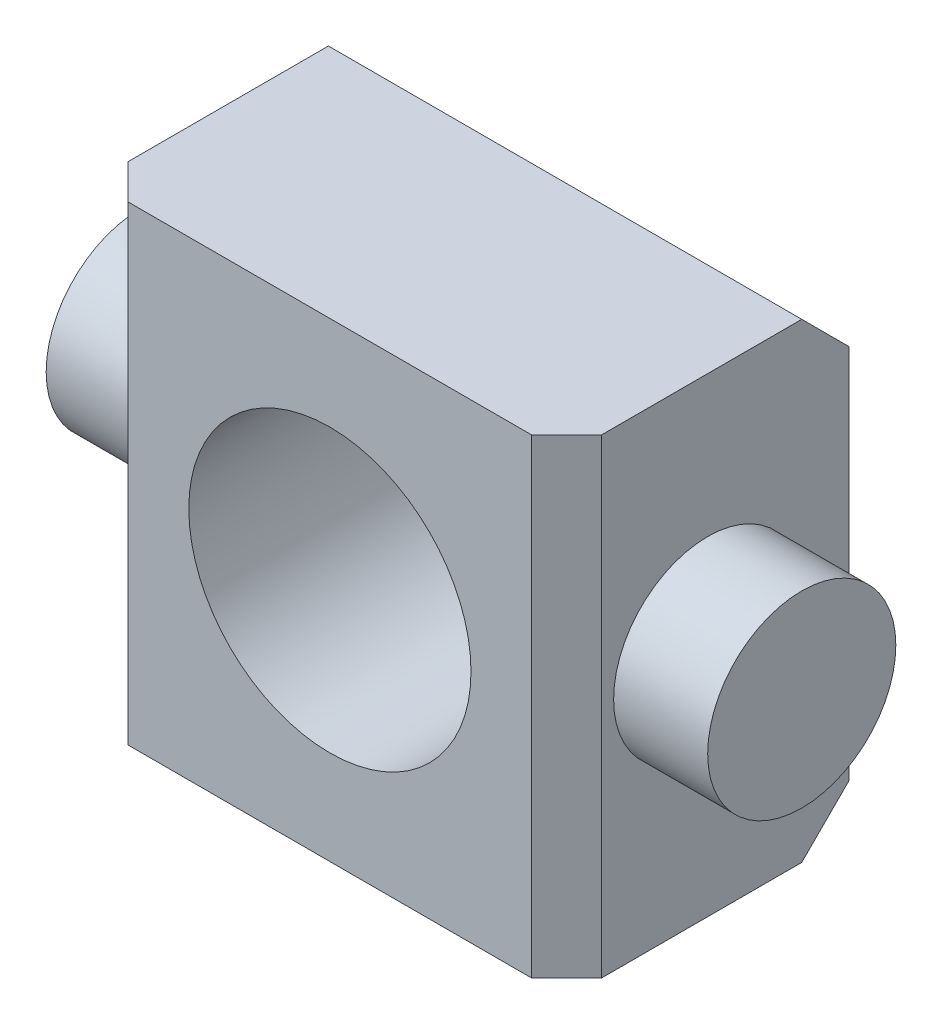
from build123d import *

# Parameters (mm, degrees)
SKETCH1_W                          = 31.9532
SKETCH1_H                          = 31.75
EXTRUDE1_DEPTH                     = 9.525
SKETCH2_R                          = 6.35
EXTRUDE2_DEPTH                     = 6.35
CHAMFER1_SIZE                      = 3.175
F_3_4_10_ACME_2C_RH_TAPPED_HOLE1_D = 19.05
CHAMFER2_SIZE                      = 2.3622


with BuildPart() as part:
    # Sketch1 → Extrude1 (new body, symmetric)
    with BuildSketch(Plane.XY):
        Rectangle(SKETCH1_W, SKETCH1_H)
    extrude(amount=EXTRUDE1_DEPTH, both=True)

    # Sketch2 → Extrude2 (add)
    with BuildSketch(Plane.ZY.offset(15.9766)):
        with Locations(Location((0, 0, 0), (0, 0, 90))):  # turned: the seam where the file's is
            Circle(SKETCH2_R)
    extrude2 = extrude(amount=EXTRUDE2_DEPTH)

    # Mirror1: Extrude2 across plane
    add(extrude2.mirror(Plane(origin=(0, 0, 0), x_dir=(0, 0, 1), z_dir=(1, 0, 0))))

    # Chamfer1
    chamfer1_edges = [part.edges().sort_by_distance(p)[0] for p in [
        (0, 15.875, -9.525),
        (0, -15.875, -9.525),
    ]]
    chamfer(chamfer1_edges, length=CHAMFER1_SIZE)

    # 3/4-10-ACME-2C-RH Tapped Hole1 (through all)
    with Locations(Plane.XY.offset(9.525)):
        with Locations((0, 0)):
            Hole(F_3_4_10_ACME_2C_RH_TAPPED_HOLE1_D / 2)

    # Chamfer2
    chamfer2_edges = [part.edges().sort_by_distance(p)[0] for p in [
        (15.9766, 0, 9.525),
        (-15.9766, 0, 9.525),
    ]]
    chamfer(chamfer2_edges, length=CHAMFER2_SIZE)


solid = part.part
